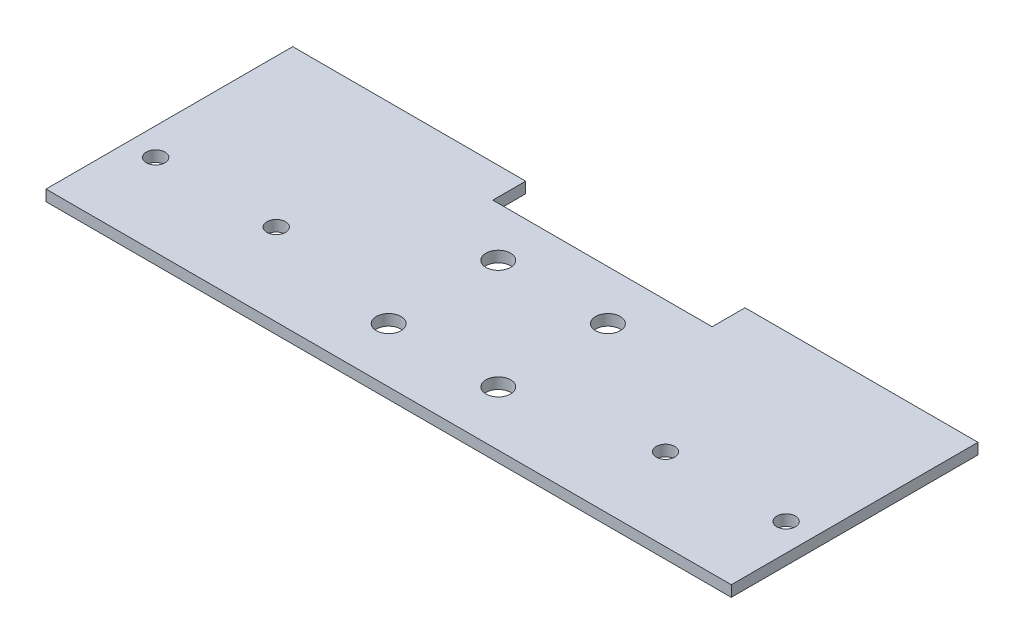
from build123d import *

# Parameters (mm, degrees)
SKETCH1_W           = 125
SKETCH1_H           = 45
BOSS_EXTRUDE1_DEPTH = 2
SKETCH2_R           = 2.25
CUT_EXTRUDE1_DEPTH  = 10
SKETCH3_R           = 1.7
CUT_EXTRUDE2_DEPTH  = 10
SKETCH4_W           = 40
SKETCH4_H           = 6
CUT_EXTRUDE3_DEPTH  = 10


with BuildPart() as part:
    # Sketch1 → Boss-Extrude1 (new body)
    with BuildSketch(Plane(origin=(0, 0, 0), x_dir=(1, 0, 0), z_dir=(0, 1, 0))):
        Rectangle(SKETCH1_W, SKETCH1_H)
    extrude(amount=BOSS_EXTRUDE1_DEPTH)

    # Sketch2 → Cut-Extrude1 (cut)
    with BuildSketch(Plane(origin=(0, 2, 0), x_dir=(1, 0, 0), z_dir=(0, 1, 0))):
        with Locations((-10, -12.5)):
            Circle(SKETCH2_R)
        with Locations((10, -12.5)):
            Circle(SKETCH2_R)
        with Locations((-10, 7.5)):
            Circle(SKETCH2_R)
        with Locations((10, 7.5)):
            Circle(SKETCH2_R)
    extrude(amount=-CUT_EXTRUDE1_DEPTH, mode=Mode.SUBTRACT)

    # Sketch3 → Cut-Extrude2 (cut)
    with BuildSketch(Plane(origin=(0, 2, 0), x_dir=(1, 0, 0), z_dir=(0, 1, 0))):
        with Locations((57.5, -7.5)):
            Circle(SKETCH3_R)
        with Locations((35.5, -7.5)):
            Circle(SKETCH3_R)
        with Locations((-35.504729394, -7.5)):
            Circle(SKETCH3_R)
        with Locations((-57.5, -7.5)):
            Circle(SKETCH3_R)
    extrude(amount=-CUT_EXTRUDE2_DEPTH, mode=Mode.SUBTRACT)

    # Sketch4 → Cut-Extrude3 (cut)
    with BuildSketch(Plane(origin=(0, 2, 0), x_dir=(1, 0, 0), z_dir=(0, 1, 0))):
        with Locations((0, 19.5)):
            Rectangle(SKETCH4_W, SKETCH4_H)
    extrude(amount=-CUT_EXTRUDE3_DEPTH, mode=Mode.SUBTRACT)


solid = part.part
